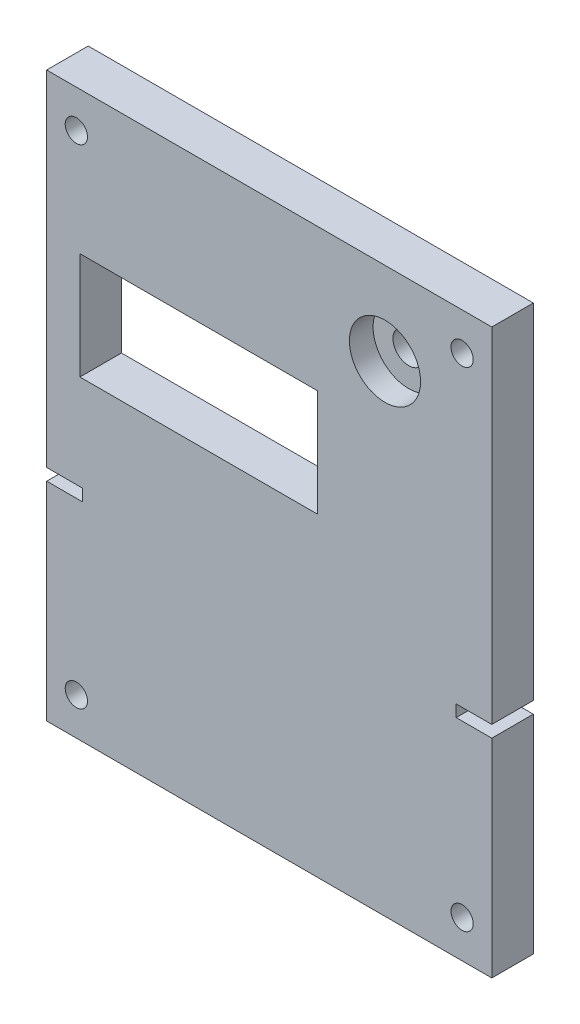
from build123d import *

# Parameters (mm, degrees)
SKETCH1_W           = 95.25
SKETCH1_H           = 120.65
BOSS_EXTRUDE1_DEPTH = 8.89
SKETCH2_OUTSIDE_W   = 128.044
SKETCH2_OUTSIDE_H   = 153.444
SKETCH2_OUTSIDE_W_2 = 95.25
SKETCH2_OUTSIDE_H_2 = 120.65
SKETCH2_OUTSIDE_R   = 2.38125
CUT_EXTRUDE2_DEPTH  = 9.89
SKETCH3_R           = 7.62
CUT_EXTRUDE3_DEPTH  = 5.08
SKETCH4_R           = 3.3655
CUT_EXTRUDE4_DEPTH  = 4.81
SKETCH5_W           = 50.8
SKETCH5_H           = 22.86
CUT_EXTRUDE5_DEPTH  = 9.89
SKETCH6_W           = 7.62
SKETCH6_H           = 2.54
CUT_EXTRUDE6_DEPTH  = 9.89


with BuildPart() as part:
    # Sketch1 → Boss-Extrude1 (new body)
    with BuildSketch(Plane.XY):
        Rectangle(SKETCH1_W, SKETCH1_H)
    extrude(amount=BOSS_EXTRUDE1_DEPTH)

    # Sketch2 outside → Cut-Extrude2 (cut, through all)
    with BuildSketch(Plane.XY.offset(8.89)):
        Rectangle(SKETCH2_OUTSIDE_W, SKETCH2_OUTSIDE_H)
        Rectangle(SKETCH2_OUTSIDE_W_2, SKETCH2_OUTSIDE_H_2, mode=Mode.SUBTRACT)
        with Locations((-41.275, 52.281666667)):
            Circle(SKETCH2_OUTSIDE_R)
        with Locations((41.275, 52.281666667)):
            Circle(SKETCH2_OUTSIDE_R)
        with Locations((41.275, -52.281666667)):
            Circle(SKETCH2_OUTSIDE_R)
        with Locations((-41.275, -52.281666667)):
            Circle(SKETCH2_OUTSIDE_R)
    extrude(amount=-CUT_EXTRUDE2_DEPTH, mode=Mode.SUBTRACT)

    # Sketch3 → Cut-Extrude3 (cut)
    with BuildSketch(Plane.XY.offset(8.89)):
        with Locations((24.765, 42.545)):
            Circle(SKETCH3_R)
    extrude(amount=-CUT_EXTRUDE3_DEPTH, mode=Mode.SUBTRACT)

    # Sketch4 → Cut-Extrude4 (cut, through all)
    with BuildSketch(Plane.XY.offset(3.81)):
        with Locations((24.765, 42.545)):
            Circle(SKETCH4_R)
    extrude(amount=-CUT_EXTRUDE4_DEPTH, mode=Mode.SUBTRACT)

    # Sketch5 → Cut-Extrude5 (cut, through all)
    with BuildSketch(Plane.XY.offset(8.89)):
        with Locations((-15.113, 18.415)):
            Rectangle(SKETCH5_W, SKETCH5_H)
    extrude(amount=-CUT_EXTRUDE5_DEPTH, mode=Mode.SUBTRACT)

    # Sketch6 → Cut-Extrude6 (cut, through all)
    with BuildSketch(Plane.XY.offset(8.89)):
        with Locations((-43.815, -14.605)):
            Rectangle(SKETCH6_W, SKETCH6_H)
        with Locations((43.815, -14.605)):
            Rectangle(SKETCH6_W, SKETCH6_H)
    extrude(amount=-CUT_EXTRUDE6_DEPTH, mode=Mode.SUBTRACT)


solid = part.part
